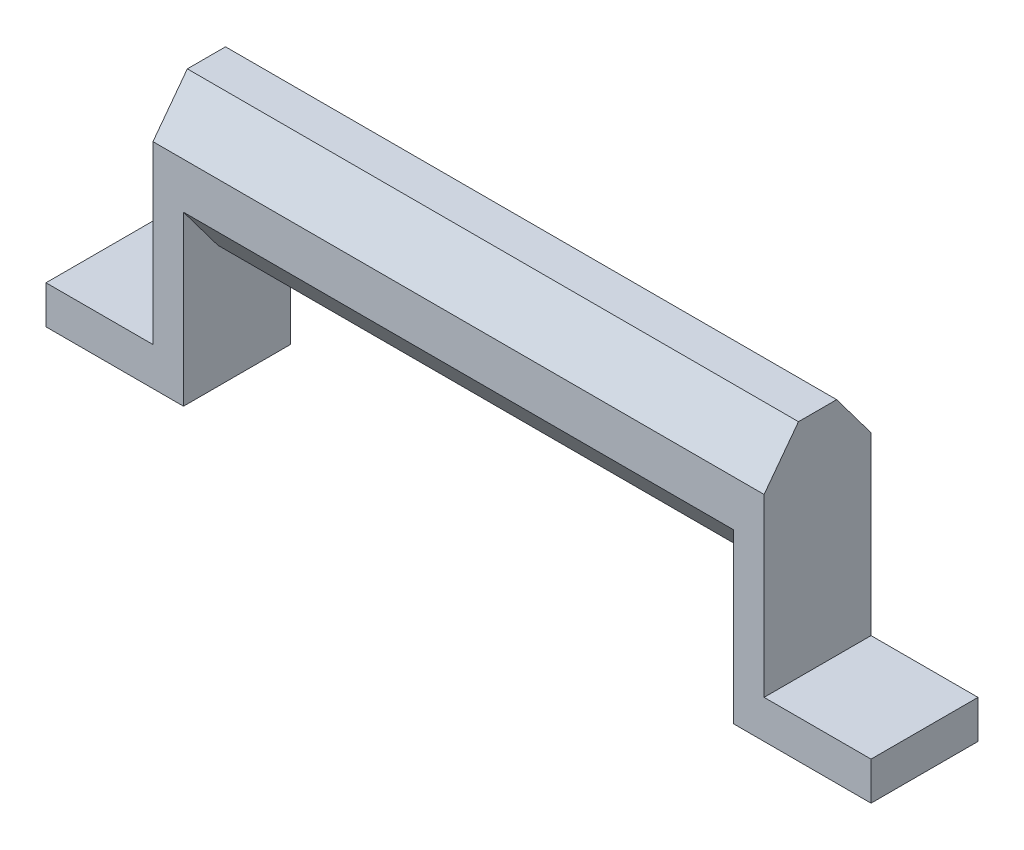
from build123d import *

# Parameters (mm, degrees)
BOSS_EXTRUDE1_DEPTH = 5.08
BOSS_EXTRUDE2_DEPTH = 50.8
SKETCH1_4_W         = 17.78
SKETCH1_4_H         = 6.35
BOSS_EXTRUDE3_DEPTH = 17.78


with BuildPart() as part:
    # Sketch1 → Boss-Extrude1 (new body)
    with BuildSketch(Plane(origin=(0, 0, 0), x_dir=(0, 0, -1), z_dir=(1, 0, 0))):
        Polygon((-8.89, 3.81), (-8.89, -31.75), (8.89, -31.75), (8.89, 3.81), (3.175, 11.43), (-3.175, 11.43), align=None)
    extrude(amount=BOSS_EXTRUDE1_DEPTH)

    # Sketch1_3 → Boss-Extrude2 (add)
    with BuildSketch(Plane(origin=(0, 0, 0), x_dir=(0, 0, -1), z_dir=(1, 0, 0))):
        Polygon((3.175, -11.43), (8.89, -3.81), (8.89, 3.81), (3.175, 11.43), (-3.175, 11.43), (-8.89, 3.81), (-8.89, -3.81), (-3.175, -11.43), align=None)
    extrude(amount=BOSS_EXTRUDE2_DEPTH)

    # Sketch1_4 → Boss-Extrude3 (add)
    with BuildSketch(Plane(origin=(0, 0, 0), x_dir=(0, 0, -1), z_dir=(1, 0, 0))):
        with Locations((0, -28.575)):
            Rectangle(SKETCH1_4_W, SKETCH1_4_H)
    extrude(amount=-BOSS_EXTRUDE3_DEPTH)

    # Mirror1: part across plane


with BuildPart() as part_1:
    add(part.part)
    add(part.part.mirror(Plane(origin=(50.8, 0, 0), x_dir=(0, 0, 1), z_dir=(1, 0, 0))))


solid = part_1.part
